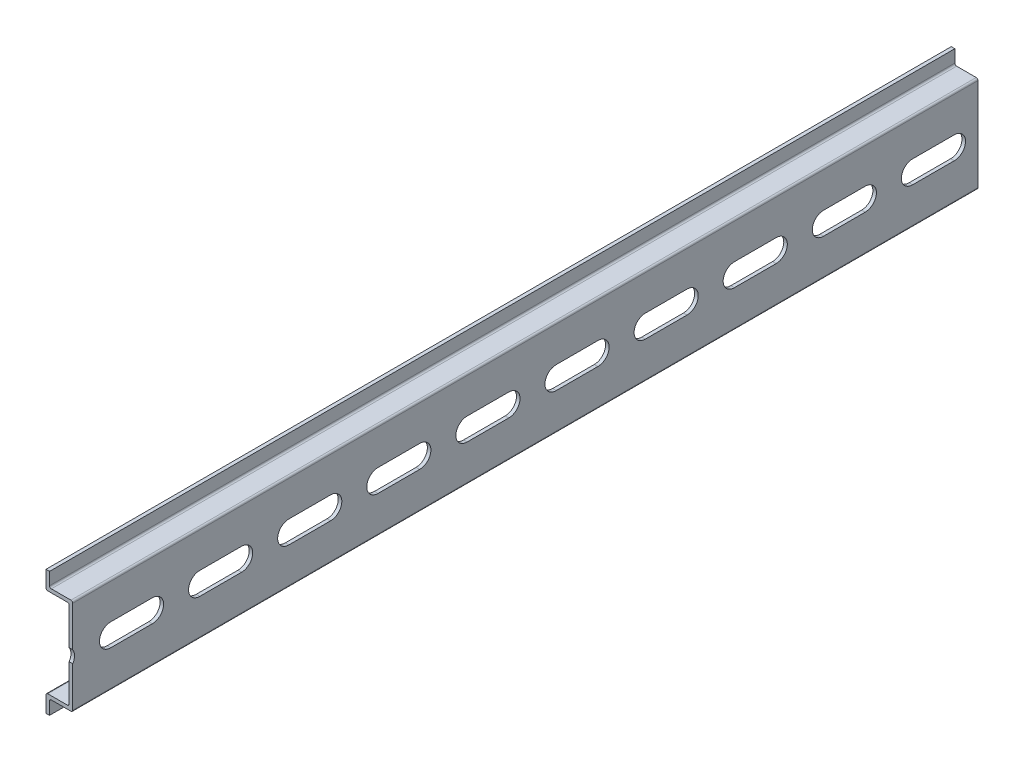
from build123d import *

# Parameters (mm, degrees)
EXTRUDE_THIN1_DEPTH = 449.2625
CUT_EXTRUDE1_START  = -8.5
CUT_EXTRUDE1_DEPTH  = 9.5
LPATTERN1_COUNT     = 18
LPATTERN1_PITCH     = 25
FILLET1_R           = 0.5
SKETCH5_W           = 13.158199176
SKETCH5_H           = 40.042206119
CUT_EXTRUDE2_DEPTH  = 195.2625


with BuildPart() as part:
    # Sketch3 → Extrude-Thin1 (new body)
    with BuildSketch(Plane.XY):
        Polygon((-6.5, 17.5), (-6.5, 13.5), (0, 13.5), (0, -13.5), (-6.5, -13.5), (-6.5, -17.5), (-7.5, -17.5), (-7.5, -12.5), (-1, -12.5), (-1, 12.5), (-7.5, 12.5), (-7.5, 17.5), align=None)
    extrude(amount=EXTRUDE_THIN1_DEPTH)

    # Sketch4 → Cut-Extrude1 (cut)
    with BuildSketch(Plane(origin=(0, 0, 0), x_dir=(0, 0, -1), z_dir=(1, 0, 0)).offset(CUT_EXTRUDE1_START)):
        with BuildLine():
            Line((-6.65, -3.15), (-18.35, -3.15))
            ThreePointArc((-18.35, -3.15), (-21.5, 0), (-18.35, 3.15))
            Line((-18.35, 3.15), (-6.65, 3.15))
            ThreePointArc((-6.65, 3.15), (-3.5, 0), (-6.65, -3.15))
        make_face()
    cut_extrude1 = extrude(amount=CUT_EXTRUDE1_DEPTH, mode=Mode.SUBTRACT)

    # LPattern1: Cut-Extrude1 ×18
    with Locations(*[(0, 0, i * LPATTERN1_PITCH) for i in range(1, LPATTERN1_COUNT)]):
        add(cut_extrude1, mode=Mode.SUBTRACT)

    # Fillet1
    fillet1_edges = [part.edges().sort_by_distance(p)[0] for p in [
        (-6.5, 13.5, 224.63125),
        (0, 13.5, 224.63125),
        (0, -13.5, 224.63125),
        (-6.5, -13.5, 224.63125),
        (-7.5, -12.5, 224.63125),
        (-1, -12.5, 224.63125),
        (-1, 12.5, 224.63125),
        (-7.5, 12.5, 224.63125),
    ]]
    fillet(fillet1_edges, radius=FILLET1_R)

    # Sketch5 → Cut-Extrude2 (cut)
    with BuildSketch(Plane.XY.offset(449.2625)):
        with Locations((-4.513311055, 1.584769395)):
            Rectangle(SKETCH5_W, SKETCH5_H)
    extrude(amount=-CUT_EXTRUDE2_DEPTH, mode=Mode.SUBTRACT)


solid = part.part
